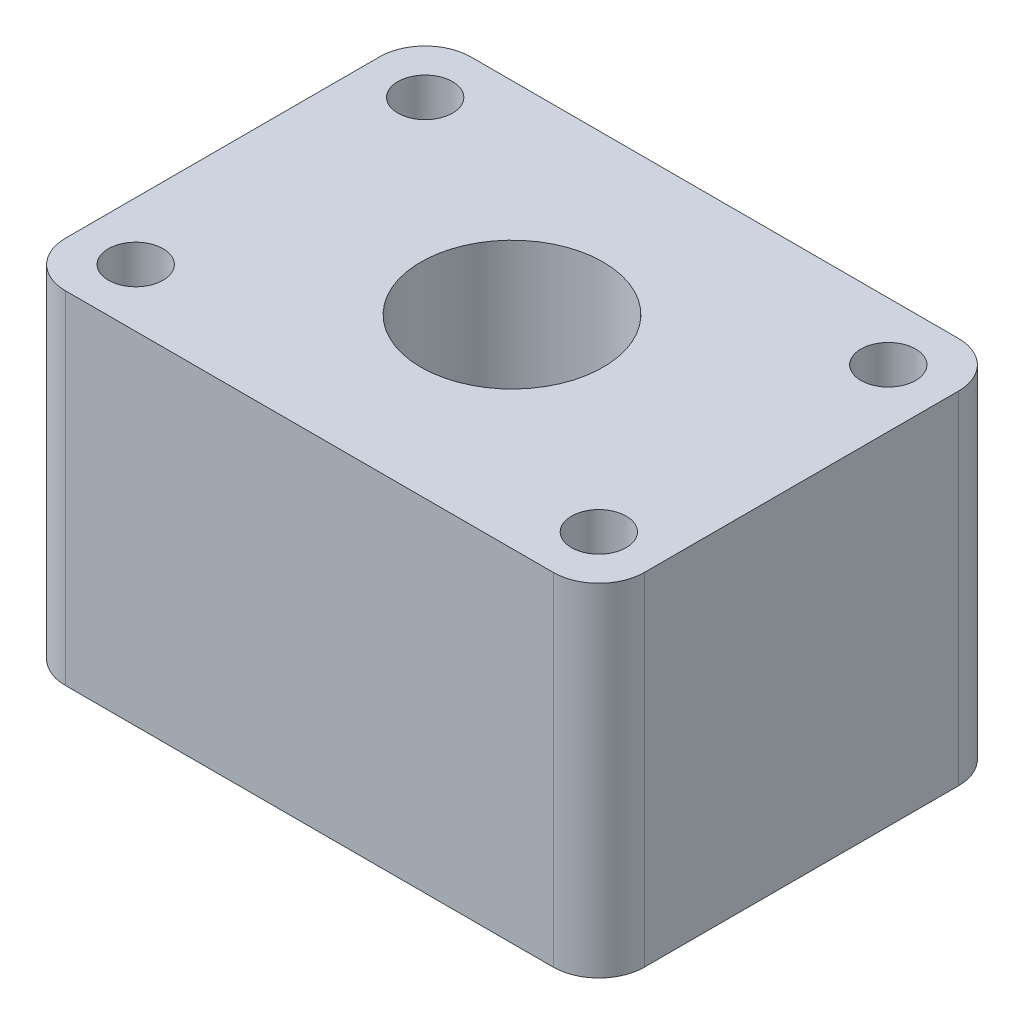
from build123d import *

# Parameters (mm, degrees)
SKETCH1_W               = 25.4
SKETCH1_H               = 17.78
BOSS_EXTRUDE1_DEPTH     = 15
SKETCH2_W               = 14
SKETCH2_H               = 9
CUT_EXTRUDE1_DEPTH      = 4
SKETCH3_R               = 4
CUT_EXTRUDE2_DEPTH      = 25
SKETCH4_R               = 1.2
CUT_EXTRUDE3_DEPTH      = 25
FILLET1_R               = 2
CHAMFER1_SIZE           = 0.5
SKETCH5_W               = 16
SKETCH5_H               = 2
CUT_EXTRUDE4_DEPTH      = 7
CUT_EXTRUDE4_DEPTH_BACK = 3


with BuildPart() as part:
    # Sketch1 → Boss-Extrude1 (new body)
    with BuildSketch(Plane(origin=(0, 0, 0), x_dir=(1, 0, 0), z_dir=(0, 1, 0))):
        Rectangle(SKETCH1_W, SKETCH1_H)
    extrude(amount=BOSS_EXTRUDE1_DEPTH)

    # Sketch2 → Cut-Extrude1 (cut)
    with BuildSketch(Plane.XZ):
        Rectangle(SKETCH2_W, SKETCH2_H)
    extrude(amount=-CUT_EXTRUDE1_DEPTH, mode=Mode.SUBTRACT)

    # Sketch3 → Cut-Extrude2 (cut)
    with BuildSketch(Plane(origin=(0, 15, 0), x_dir=(1, 0, 0), z_dir=(0, 1, 0))):
        Circle(SKETCH3_R)
    extrude(amount=-CUT_EXTRUDE2_DEPTH, mode=Mode.SUBTRACT)

    # Sketch4 → Cut-Extrude3 (cut)
    with BuildSketch(Plane.XZ):
        with Locations((-10.16, -6.35)):
            Circle(SKETCH4_R)
        with Locations((-10.16, 6.35)):
            Circle(SKETCH4_R)
        with Locations((10.16, 6.35)):
            Circle(SKETCH4_R)
        with Locations((10.16, -6.35)):
            Circle(SKETCH4_R)
    extrude(amount=-CUT_EXTRUDE3_DEPTH, mode=Mode.SUBTRACT)

    # Fillet1
    fillet1_edges = [part.edges().sort_by_distance(p)[0] for p in [
        (-12.7, 7.5, -8.89),
        (12.7, 7.5, -8.89),
        (12.7, 7.5, 8.89),
        (-12.7, 7.5, 8.89),
    ]]
    fillet(fillet1_edges, radius=FILLET1_R)

    # Chamfer1
    chamfer1_edges = [part.edges().sort_by_distance(p)[0] for p in [
        (7, 0, 0),
        (0, 0, 4.5),
        (-7, 0, 0),
        (0, 0, -4.5),
        (8.96, 0, -6.35),
        (8.96, 0, 6.35),
        (-11.36, 0, 6.35),
        (-11.36, 0, -6.35),
    ]]
    chamfer(chamfer1_edges, length=CHAMFER1_SIZE)

    # Sketch5 → Cut-Extrude4 (cut, two sides)
    with BuildSketch(Plane.XZ) as cut_extrude4_sk:
        with Locations((0, -6.39)):
            Rectangle(SKETCH5_W, SKETCH5_H)
    extrude(amount=CUT_EXTRUDE4_DEPTH, mode=Mode.SUBTRACT)
    extrude(cut_extrude4_sk.sketch, amount=-CUT_EXTRUDE4_DEPTH_BACK, mode=Mode.SUBTRACT)


solid = part.part
